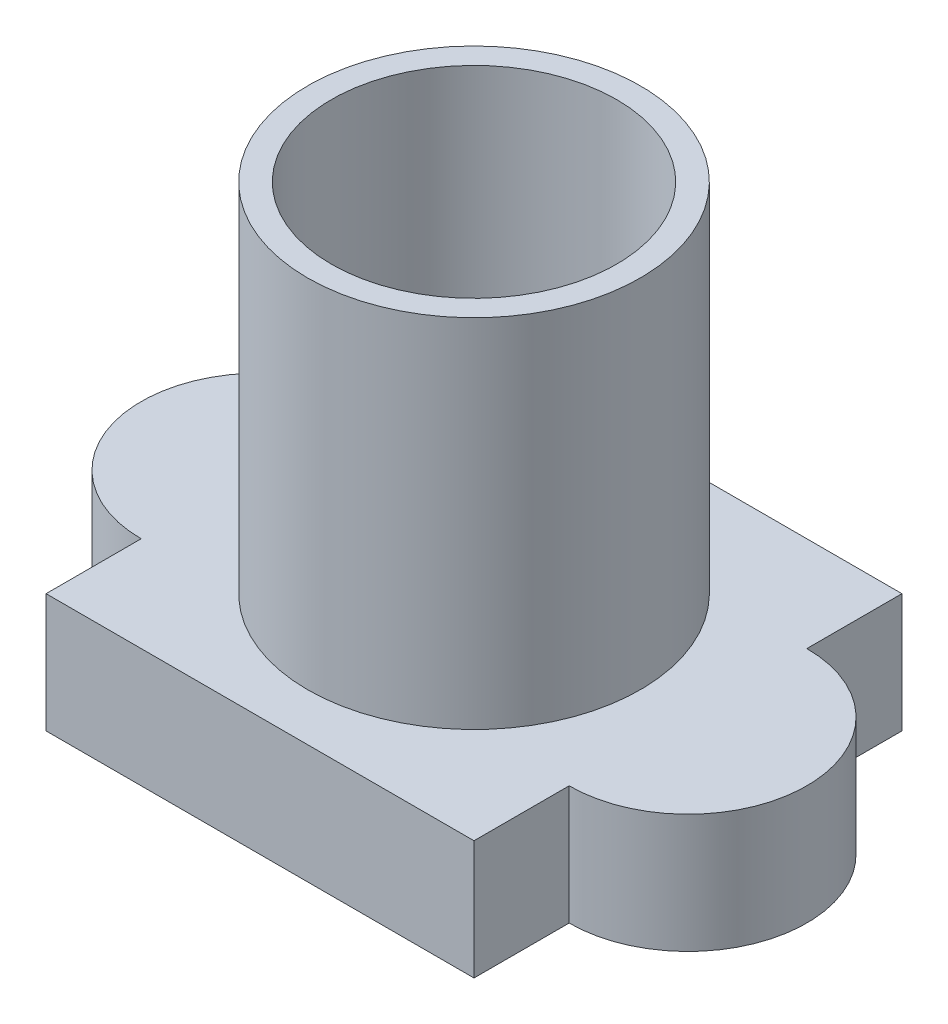
from build123d import *

# Parameters (mm, degrees)
SKETCH1_W           = 18
SKETCH1_H           = 4
BOSS_EXTRUDE1_DEPTH = 5
SKETCH2_R           = 7
BOSS_EXTRUDE2_DEPTH = 15
SKETCH3_R           = 6
CUT_EXTRUDE1_DEPTH  = 21
CUT_EXTRUDE2_DEPTH  = 4


with BuildPart() as part:
    # Sketch1 → Boss-Extrude1 (new body)
    with BuildSketch(Plane(origin=(0, 0, 0), x_dir=(1, 0, 0), z_dir=(0, 1, 0))):
        with Locations((0, 7)):
            Rectangle(SKETCH1_W, SKETCH1_H)
        with Locations((0, -7)):
            Rectangle(SKETCH1_W, SKETCH1_H)
        with BuildLine():
            Line((-9, -5), (9, -5))
            ThreePointArc((9, -5), (14, 0), (9, 5))
            Line((9, 5), (-9, 5))
            ThreePointArc((-9, 5), (-14, 0), (-9, -5))
        make_face()
    extrude(amount=BOSS_EXTRUDE1_DEPTH)

    # Sketch2 → Boss-Extrude2 (add)
    with BuildSketch(Plane(origin=(0, 5, 0), x_dir=(1, 0, 0), z_dir=(0, 1, 0))):
        Circle(SKETCH2_R)
    extrude(amount=BOSS_EXTRUDE2_DEPTH)

    # Sketch3 → Cut-Extrude1 (cut, through all)
    with BuildSketch(Plane(origin=(0, 20, 0), x_dir=(1, 0, 0), z_dir=(0, 1, 0))):
        Circle(SKETCH3_R)
    extrude(amount=-CUT_EXTRUDE1_DEPTH, mode=Mode.SUBTRACT)

    # Sketch4 → Cut-Extrude2 (cut)
    with BuildSketch(Plane.XZ):
        with BuildLine():
            Line((8, -8), (8, -3.872983346))
            ThreePointArc((8, -3.872983346), (13, 0), (8, 3.872983346))
            Line((8, 3.872983346), (8, 8))
            Line((8, 8), (-8, 8))
            Line((-8, 8), (-8, 3.872983346))
            ThreePointArc((-8, 3.872983346), (-13, 0), (-8, -3.872983346))
            Line((-8, -3.872983346), (-8, -8))
            Line((-8, -8), (8, -8))
        make_face()
    extrude(amount=-CUT_EXTRUDE2_DEPTH, mode=Mode.SUBTRACT)


solid = part.part
